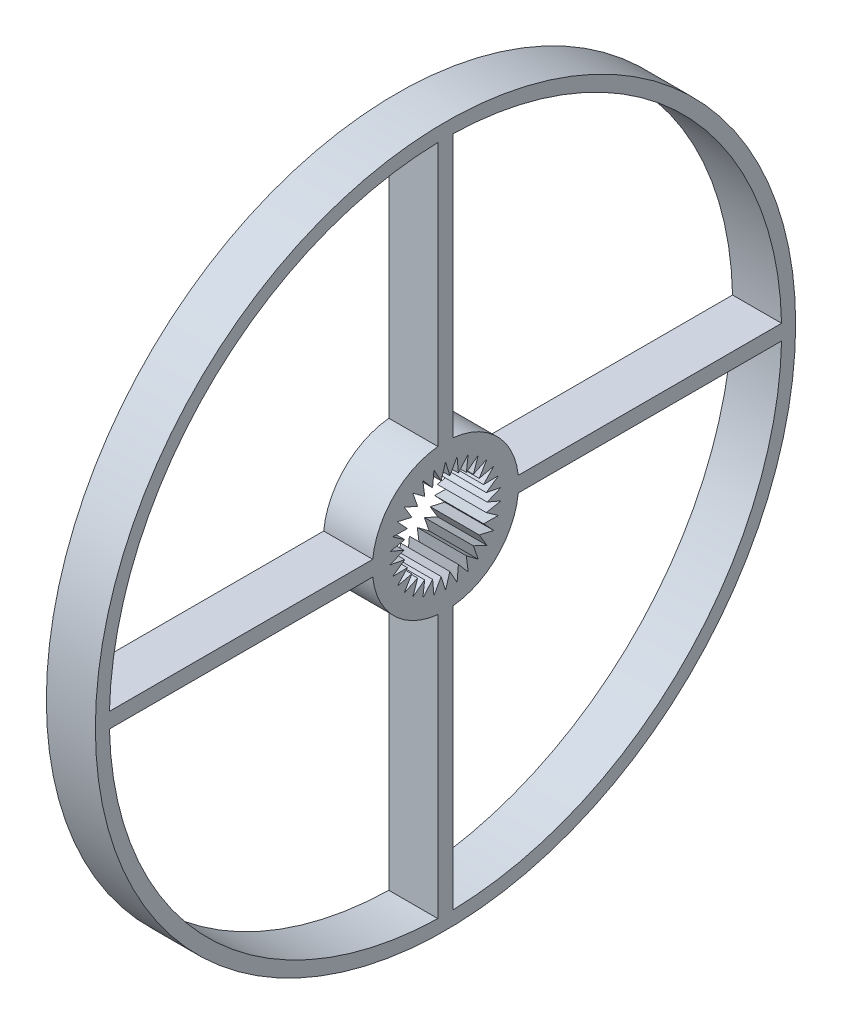
from build123d import *

# Parameters (mm, degrees)
SKETCH3_R           = 50
BOSS_EXTRUDE2_DEPTH = 7


with BuildPart() as part:
    # Sketch3 → Boss-Extrude2 (new body)
    with BuildSketch(Plane(origin=(0, 0, 0), x_dir=(0, 0, -1), z_dir=(1, 0, 0))):
        Circle(SKETCH3_R)
        Polygon((0, 7.95), (-0.621944356, 5.917405277), (-1.652897942, 7.776273426), (-1.838651117, 5.658786272), (-3.233556312, 7.262686388), (-2.975, 5.152851153), (-4.672892756, 6.431685105), (-3.981327108, 4.421711712), (-5.908001363, 5.319588321), (-4.813651117, 3.497322251), (-6.88490196, 3.975), (-5.435595473, 2.420083026), (-7.560899305, 2.456685105), (-5.819978224, 1.23707456), (-7.906449068, 0.831001283), (-5.95, 0), (-7.906449068, -0.831001283), (-5.819978224, -1.23707456), (-7.560899305, -2.456685105), (-5.435595473, -2.420083026), (-6.88490196, -3.975), (-4.813651117, -3.497322251), (-5.908001363, -5.319588321), (-3.981327108, -4.421711712), (-4.672892756, -6.431685105), (-2.975, -5.152851153), (-3.233556312, -7.262686388), (-1.838651117, -5.658786272), (-1.652897942, -7.776273426), (-0.621944356, -5.917405277), (0, -7.95), (0.621944356, -5.917405277), (1.652897942, -7.776273426), (1.838651117, -5.658786272), (3.233556312, -7.262686388), (2.975, -5.152851153), (4.672892756, -6.431685105), (3.981327108, -4.421711712), (5.908001363, -5.319588321), (4.813651117, -3.497322251), (6.88490196, -3.975), (5.435595473, -2.420083026), (7.560899305, -2.456685105), (5.819978224, -1.23707456), (7.906449068, -0.831001283), (5.95, 0), (7.906449068, 0.831001283), (5.819978224, 1.23707456), (7.560899305, 2.456685105), (5.435595473, 2.420083026), (6.88490196, 3.975), (4.813651117, 3.497322251), (5.908001363, 5.319588321), (3.981327108, 4.421711712), (4.672892756, 6.431685105), (2.975, 5.152851153), (3.233556312, 7.262686388), (1.838651117, 5.658786272), (1.652897942, 7.776273426), (0.621944356, 5.917405277), align=None, mode=Mode.SUBTRACT)
        with BuildLine():
            Line((-1.092322441, 10.392753807), (-1.092322441, 47.987569554))
            ThreePointArc((-1.092322441, 47.987569554), (-33.941125497, 33.941125497), (-47.987569554, 1.092322441))
            Line((-47.987569554, 1.092322441), (-10.392753807, 1.092322441))
            ThreePointArc((-10.392753807, 1.092322441), (-7.389265863, 7.389265863), (-1.092322441, 10.392753807))
        make_face(mode=Mode.SUBTRACT)
        with BuildLine():
            Line((1.092322441, 10.392753807), (1.092322441, 47.987569554))
            ThreePointArc((1.092322441, 47.987569554), (33.941125497, 33.941125497), (47.987569554, 1.092322441))
            Line((47.987569554, 1.092322441), (10.392753807, 1.092322441))
            ThreePointArc((10.392753807, 1.092322441), (7.389265863, 7.389265863), (1.092322441, 10.392753807))
        make_face(mode=Mode.SUBTRACT)
        with BuildLine():
            Line((10.392753807, -1.092322441), (47.987569554, -1.092322441))
            ThreePointArc((47.987569554, -1.092322441), (33.941125497, -33.941125497), (1.092322441, -47.987569554))
            Line((1.092322441, -47.987569554), (1.092322441, -10.392753807))
            ThreePointArc((1.092322441, -10.392753807), (7.389265863, -7.389265863), (10.392753807, -1.092322441))
        make_face(mode=Mode.SUBTRACT)
        with BuildLine():
            Line((-1.092322441, -10.392753807), (-1.092322441, -47.987569554))
            ThreePointArc((-1.092322441, -47.987569554), (-33.941125497, -33.941125497), (-47.987569554, -1.092322441))
            Line((-47.987569554, -1.092322441), (-10.392753807, -1.092322441))
            ThreePointArc((-10.392753807, -1.092322441), (-7.389265863, -7.389265863), (-1.092322441, -10.392753807))
        make_face(mode=Mode.SUBTRACT)
    extrude(amount=BOSS_EXTRUDE2_DEPTH)


solid = part.part
